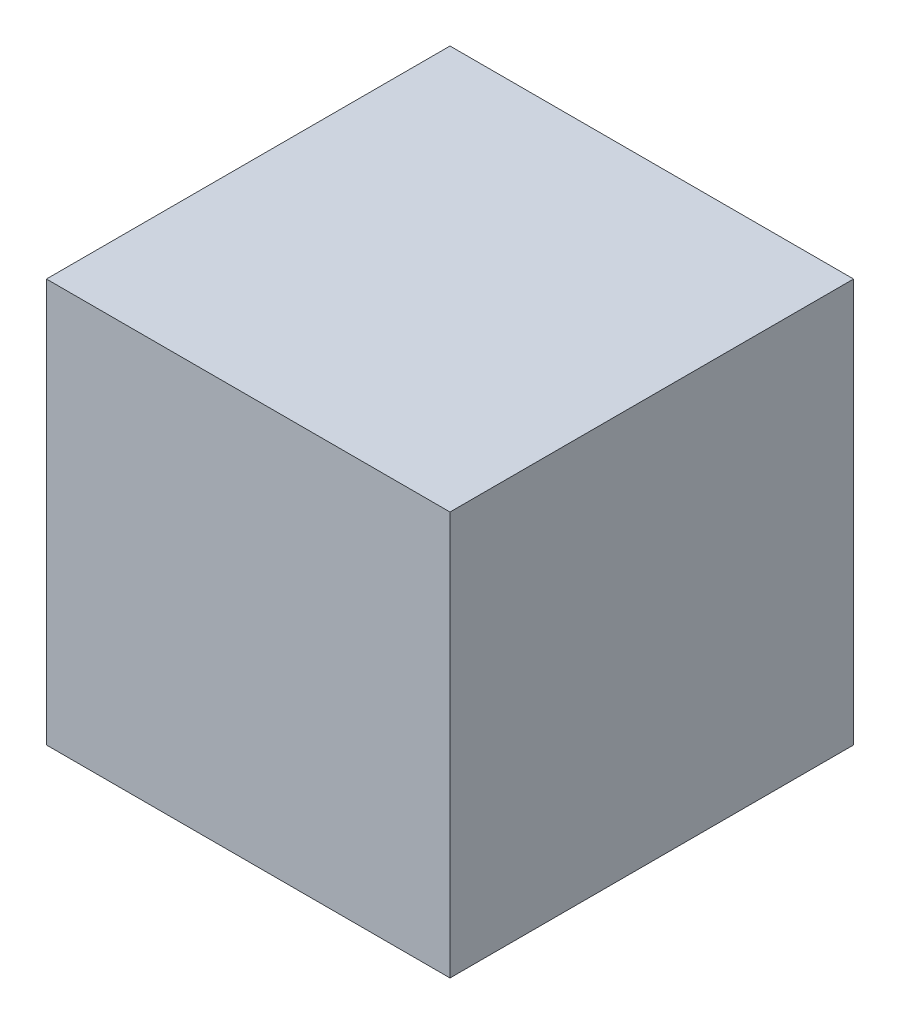
from build123d import *

# Parameters (mm, degrees)
SKETCH1_W      = 10
SKETCH1_H      = 10
EXTRUDE1_DEPTH = 10


with BuildPart() as part:
    # Sketch1 → Extrude1 (new body)
    with BuildSketch(Plane(origin=(0, 0, 0), x_dir=(1, 0, 0), z_dir=(0, 1, 0))):
        with Locations((5, 5)):
            Rectangle(SKETCH1_W, SKETCH1_H)
    extrude(amount=EXTRUDE1_DEPTH)


solid = part.part
